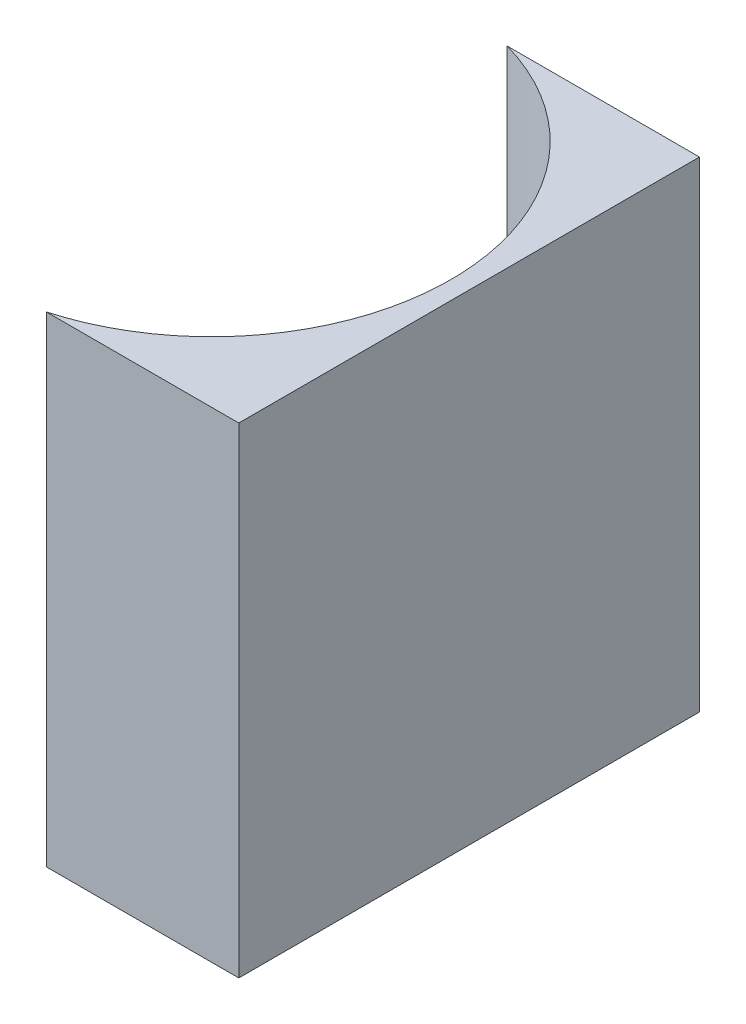
from build123d import *

# Parameters (mm, degrees)
EXTRUDE_1_DEPTH = 53


with BuildPart() as part:
    # 草图1 → 凸台-拉伸1 (new body)
    with BuildSketch(Plane(origin=(0, 0, 0), x_dir=(1, 0, 0), z_dir=(0, 1, 0))):
        with BuildLine():
            Line((0, 0), (0, -50.8))
            Line((0, -50.8), (-21.202778314, -50.8))
            ThreePointArc((-21.202778314, -50.8), (-2, -25.4), (-21.202778314, 0))
            Line((-21.202778314, 0), (0, 0))
        make_face()
    extrude(amount=EXTRUDE_1_DEPTH)


solid = part.part
